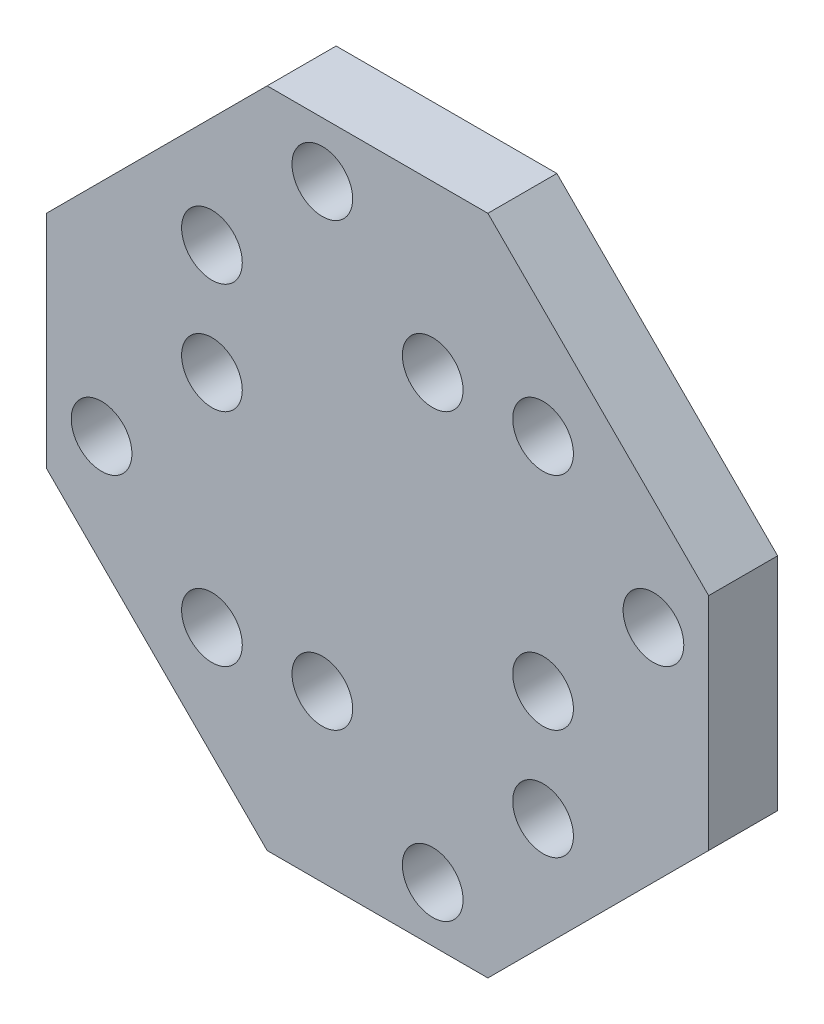
from build123d import *

# Parameters (mm, degrees)
SKIZZE1_R                       = 1.1
AUFSATZ_LINEAR_AUSTRAGEN1_DEPTH = 2.5


with BuildPart() as part:
    # Skizze1 → Aufsatz-Linear austragen1 (new body)
    with BuildSketch(Plane.XY):
        Polygon((-4, 12), (4, 12), (12, 4), (12, -4), (4, -12), (-4, -12), (-12, -4), (-12, 4), align=None)
        with Locations((-2, 10)):
            Circle(SKIZZE1_R, mode=Mode.SUBTRACT)
        with Locations((2, 6)):
            Circle(SKIZZE1_R, mode=Mode.SUBTRACT)
        with Locations((10, 2)):
            Circle(SKIZZE1_R, mode=Mode.SUBTRACT)
        with Locations((6, -2)):
            Circle(SKIZZE1_R, mode=Mode.SUBTRACT)
        with Locations((2, -10)):
            Circle(SKIZZE1_R, mode=Mode.SUBTRACT)
        with Locations((-2, -6)):
            Circle(SKIZZE1_R, mode=Mode.SUBTRACT)
        with Locations((-6, 2)):
            Circle(SKIZZE1_R, mode=Mode.SUBTRACT)
        with Locations((-10, -2)):
            Circle(SKIZZE1_R, mode=Mode.SUBTRACT)
        with Locations((-6, 6)):
            Circle(SKIZZE1_R, mode=Mode.SUBTRACT)
        with Locations((6, 6)):
            Circle(SKIZZE1_R, mode=Mode.SUBTRACT)
        with Locations((6, -6)):
            Circle(SKIZZE1_R, mode=Mode.SUBTRACT)
        with Locations((-6, -6)):
            Circle(SKIZZE1_R, mode=Mode.SUBTRACT)
    extrude(amount=AUFSATZ_LINEAR_AUSTRAGEN1_DEPTH)


solid = part.part
